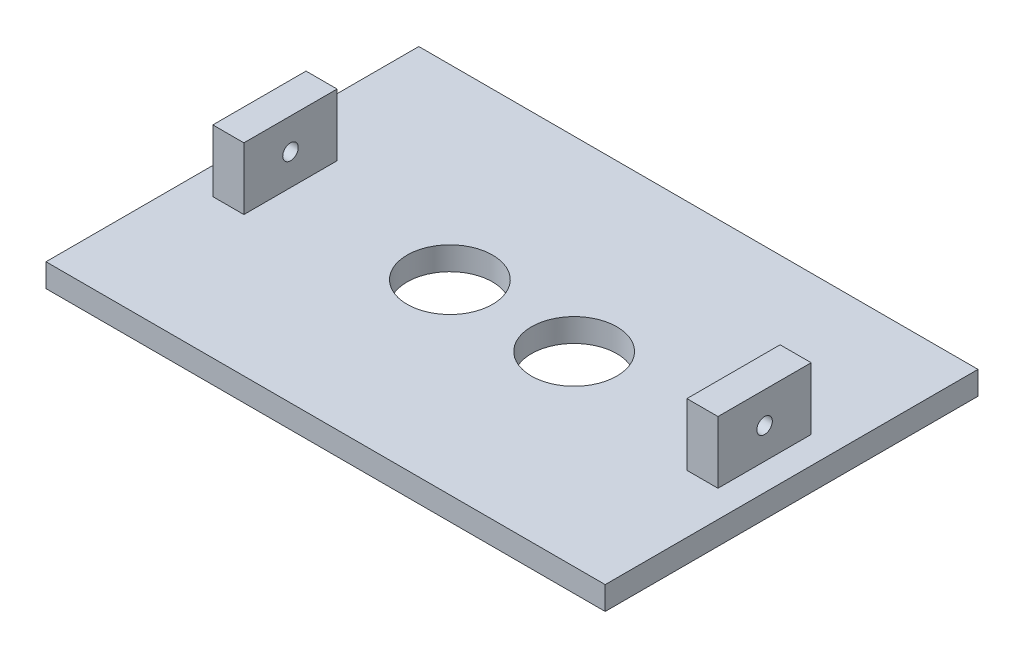
from build123d import *

# Parameters (mm, degrees)
SKETCH1_W               = 114.3
SKETCH1_H               = 76.2
MAINCOVER_DEPTH         = 4.7625
SKETCH2_W               = 6.35
SKETCH2_H               = 19.05
BOSS_EXTRUDE1_DEPTH     = 12.7
SKETCH3_R               = 1.5875
CUT_EXTRUDE1_DEPTH      = 6.5245
CUT_EXTRUDE1_DEPTH_BACK = 109.7755
SKETCH4_R               = 8.73125
CUT_EXTRUDE2_DEPTH      = 18.4625


with BuildPart() as part:
    # Sketch1 → MainCover (new body)
    with BuildSketch(Plane(origin=(0, 0, 0), x_dir=(1, 0, 0), z_dir=(0, 1, 0))):
        Rectangle(SKETCH1_W, SKETCH1_H)
    extrude(amount=MAINCOVER_DEPTH)

    # Sketch2 → Boss-Extrude1 (add)
    with BuildSketch(Plane(origin=(0, 4.7625, 0), x_dir=(1, 0, 0), z_dir=(0, 1, 0))):
        with Locations((-48.4505, 0)):
            Rectangle(SKETCH2_W, SKETCH2_H)
        with Locations((48.4505, 0)):
            Rectangle(SKETCH2_W, SKETCH2_H)
    extrude(amount=BOSS_EXTRUDE1_DEPTH)

    # Sketch3 → Cut-Extrude1 (cut, two sides)
    with BuildSketch(Plane.ZY.offset(51.6255)) as cut_extrude1_sk:
        with Locations((0, 11.1125)):
            Circle(SKETCH3_R)
    extrude(amount=CUT_EXTRUDE1_DEPTH, mode=Mode.SUBTRACT)
    extrude(cut_extrude1_sk.sketch, amount=-CUT_EXTRUDE1_DEPTH_BACK, mode=Mode.SUBTRACT)

    # Sketch4 → Cut-Extrude2 (cut, through all)
    with BuildSketch(Plane.XZ):
        with Locations((12.7, 0)):
            Circle(SKETCH4_R)
        with Locations((-12.7, 0)):
            Circle(SKETCH4_R)
    extrude(amount=-CUT_EXTRUDE2_DEPTH, mode=Mode.SUBTRACT)


solid = part.part
